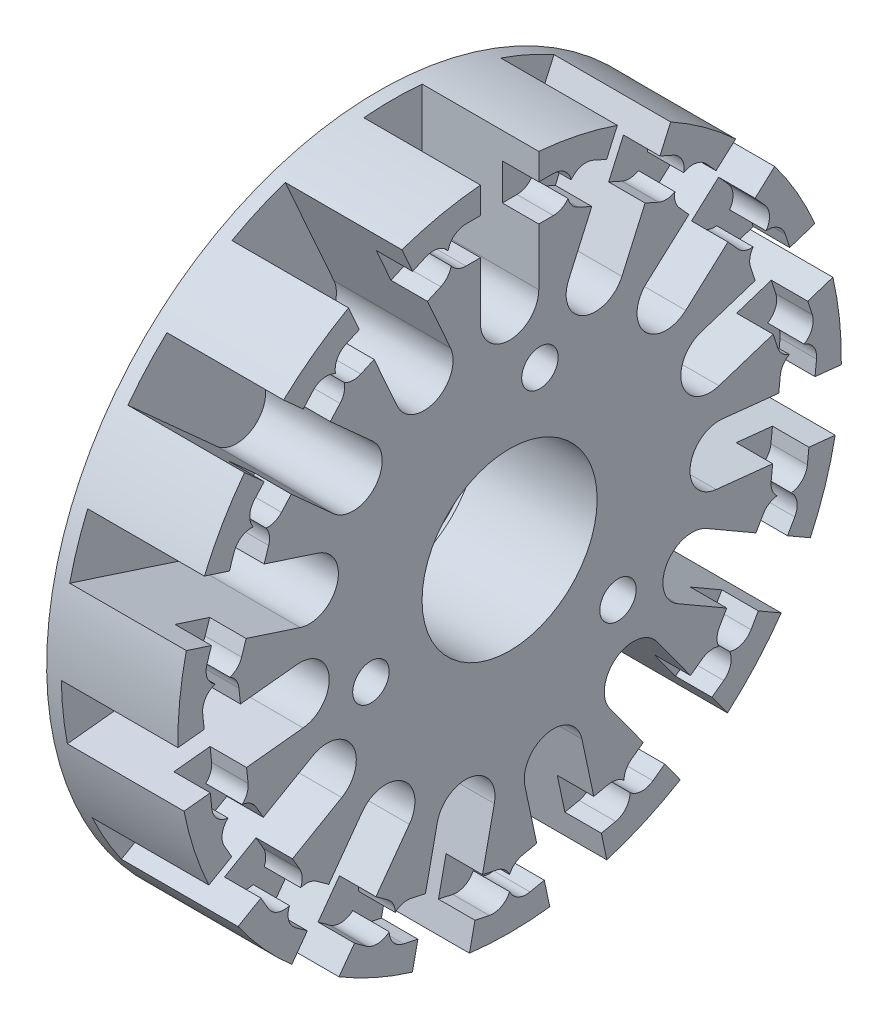
from build123d import *

# Parameters (mm, degrees)
SKETCH1_R           = 22.75
SKETCH1_R_2         = 6.005
BOSS_EXTRUDE1_DEPTH = 9
CUT_EXTRUDE1_DEPTH  = 8
CUT_EXTRUDE2_DEPTH  = 2.5
CIRPATTERN1_COUNT   = 15
CIRPATTERN2_COUNT   = 3
SKETCH8_R           = 6.8
CUT_EXTRUDE4_DEPTH  = 0.8
CIRPATTERN3_COUNT   = 5


with BuildPart() as part:
    # Sketch1 → Boss-Extrude1 (new body)
    with BuildSketch(Plane(origin=(0, 0, 0), x_dir=(0, 0, -1), z_dir=(1, 0, 0))):
        Circle(SKETCH1_R)
        Circle(SKETCH1_R_2, mode=Mode.SUBTRACT)
    extrude(amount=BOSS_EXTRUDE1_DEPTH)

    # Sketch2 → Cut-Extrude1 (cut)
    with BuildSketch(Plane(origin=(9, 0, 0), x_dir=(0, 0, -1), z_dir=(1, 0, 0))):
        with BuildLine():
            Line((-2, 22.75), (2, 22.75))
            Line((2, 22.75), (2, 14.45))
            ThreePointArc((2, 14.45), (0, 12.45), (-2, 14.45))
            Line((-2, 14.45), (-2, 22.75))
        make_face()
    cut_extrude1 = extrude(amount=-CUT_EXTRUDE1_DEPTH, mode=Mode.SUBTRACT)

    # Sketch3 → Cut-Extrude2 (cut)
    with BuildSketch(Plane(origin=(9, 0, 0), x_dir=(0, 0, -1), z_dir=(1, 0, 0))):
        with BuildLine():
            Line((-3, 20.85), (3, 20.85))
            ThreePointArc((3, 20.85), (4.25, 19.6), (3, 18.35))
            Line((3, 18.35), (-3, 18.35))
            ThreePointArc((-3, 18.35), (-4.25, 19.6), (-3, 20.85))
        make_face()
    cut_extrude2 = extrude(amount=-CUT_EXTRUDE2_DEPTH, mode=Mode.SUBTRACT)

    # CirPattern1: Cut-Extrude1, Cut-Extrude2 ×15 about axis
    cirpattern1_axis = Axis((0, 0, 0), (1, 0, 0))
    for i in range(1, CIRPATTERN1_COUNT):
        add(cut_extrude1.rotate(cirpattern1_axis, i * 360 / CIRPATTERN1_COUNT), mode=Mode.SUBTRACT)
        add(cut_extrude2.rotate(cirpattern1_axis, i * 360 / CIRPATTERN1_COUNT), mode=Mode.SUBTRACT)

    # Sketch5 → Tap Drill for M3x0.5 Tap1 (revolve, cut)
    with BuildSketch(Plane(origin=(9, 9.781476007, -2.079116908), x_dir=(0, 0, -1), z_dir=(0, 1, 0))):
        Polygon((0, 0), (0, 7.751075774), (1.25, 7), (1.25, 0), align=None)
    tap_drill_for_m3x0_5_tap1 = revolve(axis=Axis((15.35, 9.781476007, -2.079116908), (-1, 0, 0)), mode=Mode.SUBTRACT)

    # CirPattern2: Tap Drill for M3x0.5 Tap1 ×3 about axis
    cirpattern2_axis = Axis((0, 0, 0), (1, 0, 0))
    for i in range(1, CIRPATTERN2_COUNT):
        add(tap_drill_for_m3x0_5_tap1.rotate(cirpattern2_axis, i * 360 / CIRPATTERN2_COUNT), mode=Mode.SUBTRACT)

    # Sketch8 → Cut-Extrude4 (cut)
    with BuildSketch(Plane.ZY):
        Circle(SKETCH8_R)
    extrude(amount=-CUT_EXTRUDE4_DEPTH, mode=Mode.SUBTRACT)

    # Sketch9 → Tap Drill for M2x0.4 Tap1 (revolve, cut)
    with BuildSketch(Plane(origin=(0, 20.296562715, -4.314167584), x_dir=(0, 0, 1), z_dir=(0, 1, 0))):
        Polygon((0, 0), (0, 5.980688495), (0.8, 5.5), (0.8, 0), align=None)
    tap_drill_for_m2x0_4_tap1 = revolve(axis=Axis((-6.35, 20.296562715, -4.314167584), (1, 0, 0)), mode=Mode.SUBTRACT)

    # CirPattern3: Tap Drill for M2x0.4 Tap1 ×5 about axis
    cirpattern3_axis = Axis((0, 0, 0), (1, 0, 0))
    for i in range(1, CIRPATTERN3_COUNT):
        add(tap_drill_for_m2x0_4_tap1.rotate(cirpattern3_axis, i * 360 / CIRPATTERN3_COUNT), mode=Mode.SUBTRACT)


solid = part.part
